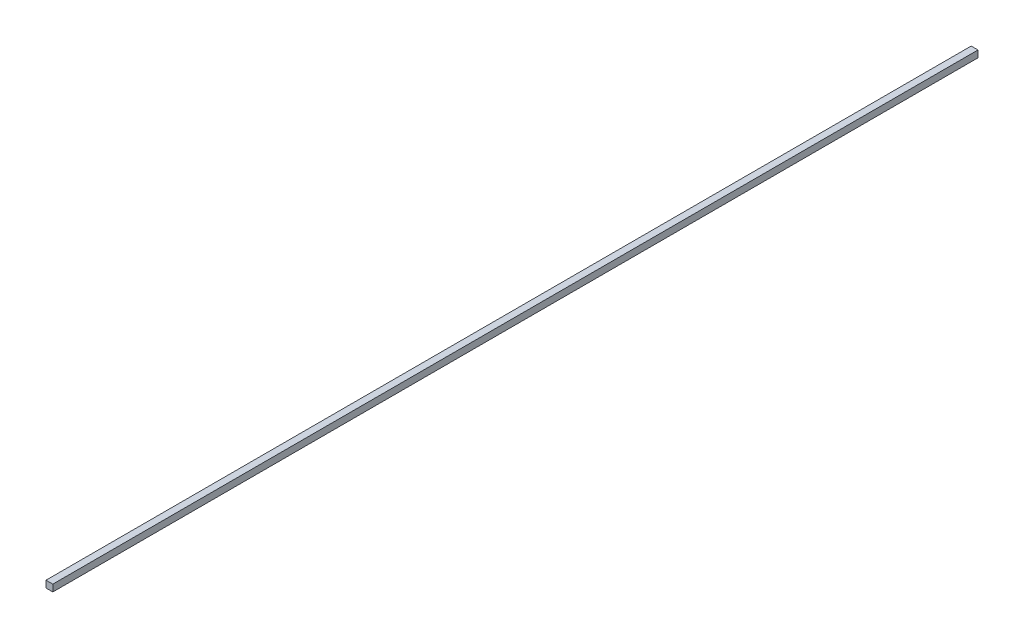
from build123d import *

# Parameters (mm, degrees)
ESBO_O1_W                = 35
ESBO_O1_H                = 35
RESSALTO_EXTRUS_O1_DEPTH = 4750


with BuildPart() as part:
    # Esboço1 → Ressalto-extrusão1 (new body)
    with BuildSketch(Plane.XY):
        with Locations((17.5, 17.5)):
            Rectangle(ESBO_O1_W, ESBO_O1_H)
    extrude(amount=RESSALTO_EXTRUS_O1_DEPTH)


solid = part.part
